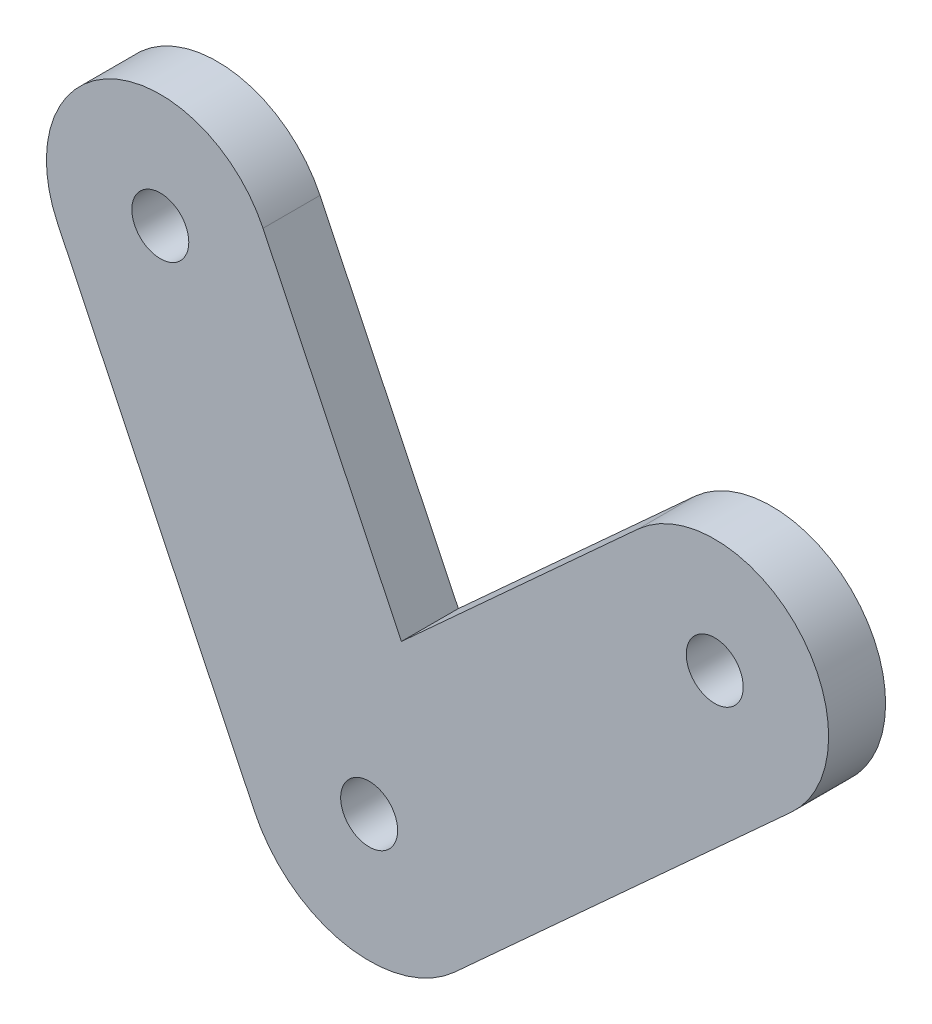
from build123d import *

# Parameters (mm, degrees)
SKETCH1_R           = 1.5875
BOSS_EXTRUDE2_DEPTH = 3.175


with BuildPart() as part:
    # Sketch1 → Boss-Extrude2 (new body)
    with BuildSketch(Plane.XY):
        with BuildLine():
            Line((28.513090943, 6.060087425), (9.748066048, -11.042213745))
            ThreePointArc((9.748066048, -11.042213745), (3.618271725, -12.760881788), (-1.418497452, -8.867405893))
            Line((-1.418497452, -8.867405893), (-12.393710832, 14.027125243))
            ThreePointArc((-12.393710832, 14.027125243), (-9.412621674, 22.498140969), (-0.941605948, 19.517051811))
            Line((-0.941605948, 19.517051811), (6.771217457, 3.427936321))
            Line((6.771217457, 3.427936321), (19.958325371, 15.446566318))
            ThreePointArc((19.958325371, 15.446566318), (28.928947603, 15.030709658), (28.513090943, 6.060087425))
        make_face()
        with Locations((-6.66765839, 16.772088527)):
            Circle(SKETCH1_R, mode=Mode.SUBTRACT)
        with Locations((24.235708157, 10.753326872)):
            Circle(SKETCH1_R, mode=Mode.SUBTRACT)
        with Locations((4.973339626, -5.803277809)):
            Circle(SKETCH1_R, mode=Mode.SUBTRACT)
    extrude(amount=BOSS_EXTRUDE2_DEPTH)


solid = part.part
